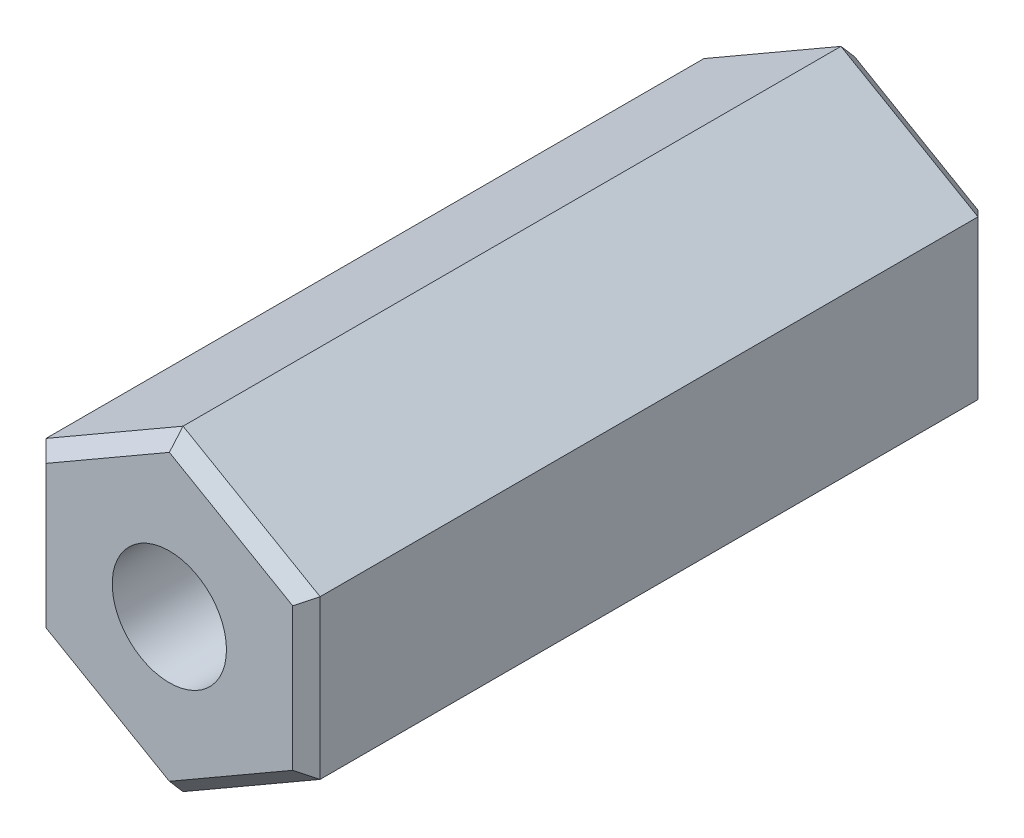
from build123d import *

# Parameters (mm, degrees)
BOSS_EXTRUDE1_DEPTH   = 15
M3_TAPPED_HOLE1_D     = 2.5
M3_TAPPED_HOLE1_DEPTH = 6
M3_TAPPED_HOLE1_TIP   = 0.751075774
M3_TAPPED_HOLE2_D     = 2.5
M3_TAPPED_HOLE2_DEPTH = 7
M3_TAPPED_HOLE2_TIP   = 0.751075774
CHAMFER1_SIZE         = 0.3


with BuildPart() as part:
    # Sketch1 → Boss-Extrude1 (new body)
    with BuildSketch(Plane.XY):
        Polygon((0, 3.464101615), (-3, 1.732050808), (-3, -1.732050808), (0, -3.464101615), (3, -1.732050808), (3, 1.732050808), align=None)
    extrude(amount=BOSS_EXTRUDE1_DEPTH)

    # M3 Tapped Hole1
    with Locations(Plane.XY.offset(15)):
        with Locations((0, 0)):
            Hole(M3_TAPPED_HOLE1_D / 2, depth=M3_TAPPED_HOLE1_DEPTH)
            with Locations((0, 0, -(M3_TAPPED_HOLE1_DEPTH + M3_TAPPED_HOLE1_TIP / 2))):  # 118° drill point
                Cone(0, M3_TAPPED_HOLE1_D / 2, M3_TAPPED_HOLE1_TIP, mode=Mode.SUBTRACT)

    # M3 Tapped Hole2
    with Locations(Plane(origin=(0, 0, 0), x_dir=(-1, 0, 0), z_dir=(0, 0, -1))):
        with Locations((0, 0)):
            Hole(M3_TAPPED_HOLE2_D / 2, depth=M3_TAPPED_HOLE2_DEPTH)
            with Locations((0, 0, -(M3_TAPPED_HOLE2_DEPTH + M3_TAPPED_HOLE2_TIP / 2))):  # 118° drill point
                Cone(0, M3_TAPPED_HOLE2_D / 2, M3_TAPPED_HOLE2_TIP, mode=Mode.SUBTRACT)

    # Chamfer1
    chamfer1_edges = [part.edges().sort_by_distance(p)[0] for p in [
        (-3, 0, 15),
        (-1.5, -2.598076211, 15),
        (1.5, -2.598076211, 15),
        (3, 0, 15),
        (1.5, 2.598076211, 15),
        (3, 0, 0),
        (1.5, -2.598076211, 0),
        (-1.5, -2.598076211, 0),
        (-1.5, 2.598076211, 15),
        (-3, 0, 0),
        (-1.5, 2.598076211, 0),
        (1.5, 2.598076211, 0),
    ]]
    chamfer(chamfer1_edges, length=CHAMFER1_SIZE)


solid = part.part
